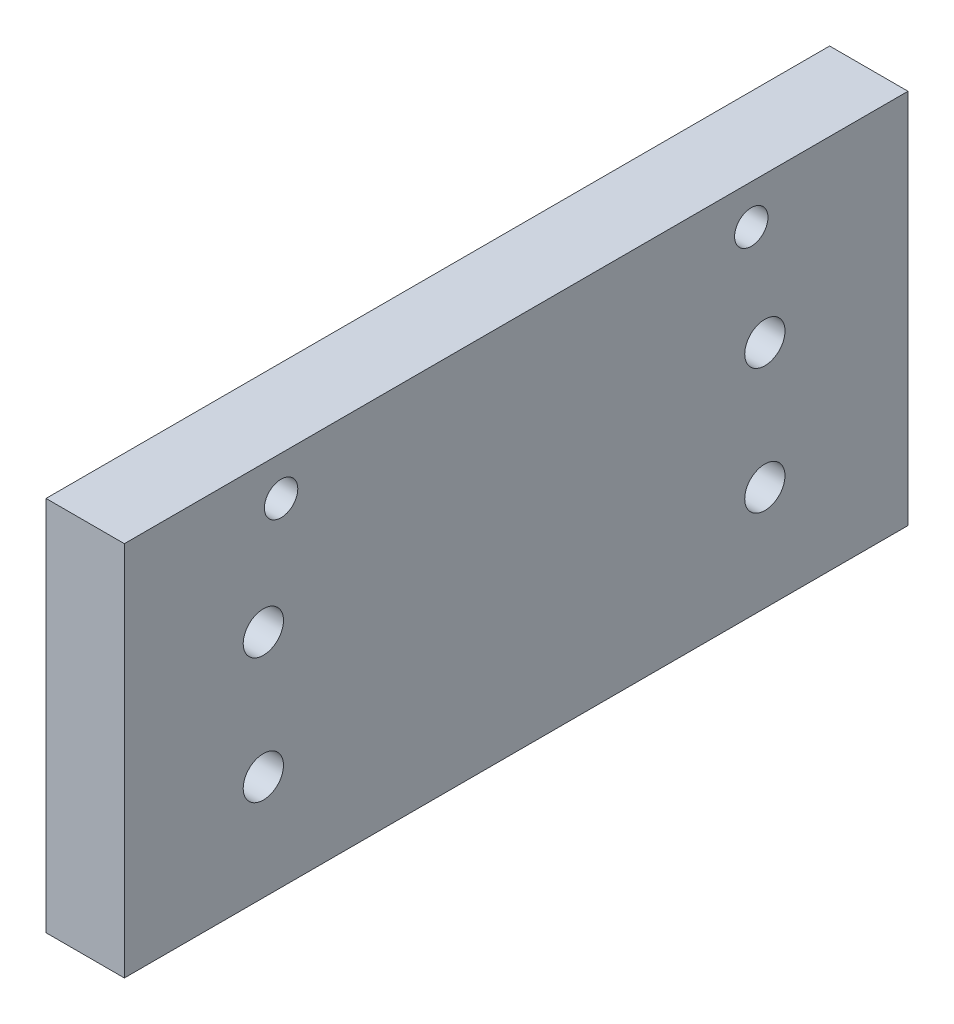
from build123d import *

# Parameters (mm, degrees)
SKETCH1_W                           = 63.5
SKETCH1_H                           = 30.48
BOSS_EXTRUDE1_DEPTH                 = 6.35
TAP_DRILL_FOR_6_32_TAP1_D           = 2.7051
TAP_DRILL_FOR_6_32_TAP1_DEPTH       = 6.35
TAP_DRILL_FOR_6_32_TAP1_CSINK_D     = 3.9751
TAP_DRILL_FOR_6_32_TAP1_CSINK_ANGLE = 90
LPATTERN1_COUNT                     = 2
LPATTERN1_PITCH                     = 40.64
LPATTERN1_COUNT_DIR2                = 2
LPATTERN1_PITCH_DIR2                = 10.16


with BuildPart() as part:
    # Sketch1 → Boss-Extrude1 (new body)
    with BuildSketch(Plane(origin=(0, 0, 0), x_dir=(0, 0, -1), z_dir=(1, 0, 0))):
        with Locations((-28.514872299, 20.201128374)):
            Rectangle(SKETCH1_W, SKETCH1_H)
    extrude(amount=BOSS_EXTRUDE1_DEPTH)

    # Tap Drill for #6-32 Tap1
    with Locations(Plane.ZY):
        with Locations((9.464872299, 32.266128374), (47.564872299, 32.266128374)):
            CounterSinkHole(TAP_DRILL_FOR_6_32_TAP1_D / 2, TAP_DRILL_FOR_6_32_TAP1_CSINK_D / 2, depth=TAP_DRILL_FOR_6_32_TAP1_DEPTH, counter_sink_angle=TAP_DRILL_FOR_6_32_TAP1_CSINK_ANGLE)

    # Sketch8 → #5 Clearance Hole1 (revolve, cut)
    with BuildSketch(Plane(origin=(0, 23.60868099, 8.363470458), x_dir=(0, 0, 1), z_dir=(0, 1, 0))):
        Polygon((0, 0), (0, 13.680574487), (1.63195, 12.7), (1.63195, 0), align=None)
    f_5_clearance_hole1 = revolve(axis=Axis((-6.35, 23.60868099, 8.363470458), (1, 0, 0)), mode=Mode.SUBTRACT)

    # LPattern1: 5 Clearance Hole1 2 × 2
    with Locations(*[(0, -j * LPATTERN1_PITCH_DIR2, i * LPATTERN1_PITCH) for i in range(LPATTERN1_COUNT) for j in range(LPATTERN1_COUNT_DIR2) if (i, j) != (0, 0)]):
        add(f_5_clearance_hole1, mode=Mode.SUBTRACT)


solid = part.part
